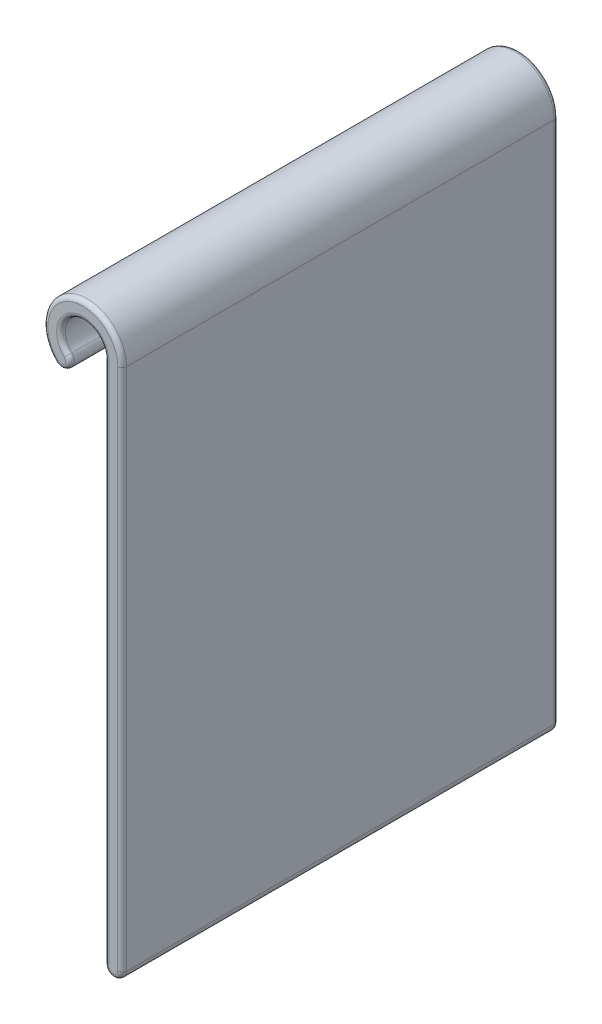
from build123d import *

# Parameters (mm, degrees)
BOSS_EXTRUDE1_DEPTH = 63.5
FILLET1_R           = 0.635


with BuildPart() as part:
    # Sketch1 → Boss-Extrude1 (new body)
    with BuildSketch(Plane.XY):
        with BuildLine():
            Line((3.175, 0), (3.175, -76.2))
            ThreePointArc((3.175, -76.2), (4.445, -77.47), (5.715, -76.2))
            Line((5.715, -76.2), (5.715, 0))
            ThreePointArc((5.715, 0), (-2.187035816, 5.279971528), (-4.041115254, -4.041115254))
            ThreePointArc((-4.041115254, -4.041115254), (-2.24506403, -4.041115254), (-2.24506403, -2.24506403))
            ThreePointArc((-2.24506403, -2.24506403), (-1.215019898, 2.933317516), (3.175, 0))
        make_face()
    extrude(amount=BOSS_EXTRUDE1_DEPTH)

    # Fillet1
    fillet1_edges = [part.edges().sort_by_distance(p)[0] for p in [
        (-2.187035816, 5.279971528, 63.5),
        (-2.24506403, -4.041115254, 63.5),
        (-1.215019898, 2.933317516, 63.5),
        (3.175, -38.1, 63.5),
        (4.445, -77.47, 63.5),
        (3.175, -38.1, 0),
        (-1.215019898, 2.933317516, 0),
        (-2.24506403, -4.041115254, 0),
        (5.715, -38.1, 63.5),
        (-2.187035816, 5.279971528, 0),
        (5.715, -38.1, 0),
        (4.445, -77.47, 0),
    ]]
    fillet(fillet1_edges, radius=FILLET1_R)


solid = part.part
